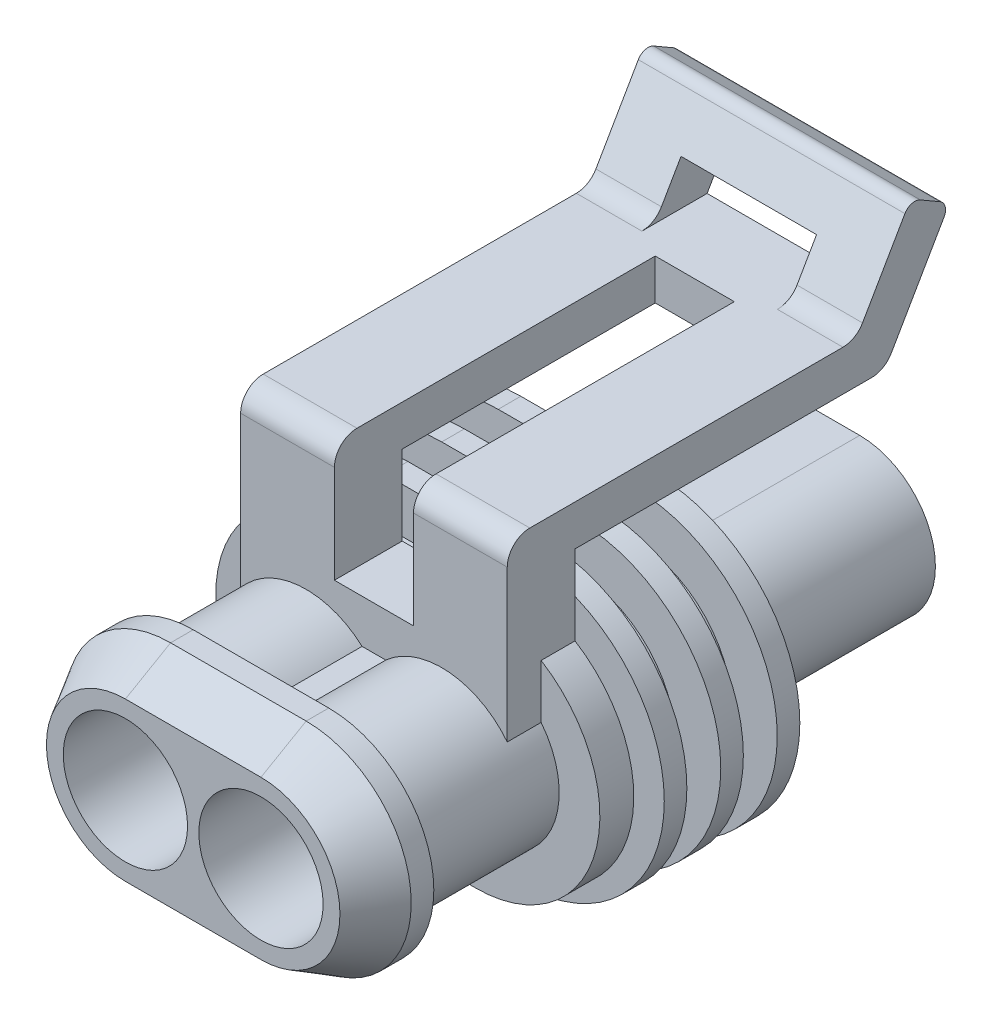
from build123d import *
from OCP.BRepFilletAPI import BRepFilletAPI_MakeChamfer

# Parameters (mm, degrees)
SKETCH1_R          = 2.75
EXTRUDE1_DEPTH     = 6.5
SKETCH2_R          = 2.75
EXTRUDE2_DEPTH     = 3
CHAMFER1_SIZE      = 2
CHAMFER1_SIZE2     = 1.154700538
SKETCH4_R          = 2.75
EXTRUDE3_DEPTH     = 1.5
EXTRUDE4_DEPTH     = 5.9
EXTRUDE5_DEPTH     = 15.5
CUT_EXTRUDE1_DEPTH = 3
CUT_EXTRUDE2_DEPTH = 1.75


with BuildPart() as part:
    # Sketch1 → Extrude1 (new body)
    with BuildSketch(Plane.XY):
        with BuildLine():
            Line((0.524621241, 2.75), (-0.524621241, 2.75))
            ThreePointArc((-0.524621241, 2.75), (-6.7, 0), (-0.524621241, -2.75))
            Line((-0.524621241, -2.75), (0.524621241, -2.75))
            ThreePointArc((0.524621241, -2.75), (6.7, 0), (0.524621241, 2.75))
        make_face()
        with Locations(Location((3, 0, 0), (0, 0, 180))):
            Circle(SKETCH1_R, mode=Mode.SUBTRACT)
        with Locations(Location((-3, 0, 0), (0, 0, 180))):
            Circle(SKETCH1_R, mode=Mode.SUBTRACT)
    extrude(amount=EXTRUDE1_DEPTH)

    # Sketch2 → Extrude2 (add)
    with BuildSketch(Plane.XY.offset(6.5)):
        with BuildLine():
            Line((3, 4.65), (-3, 4.65))
            ThreePointArc((-3, 4.65), (-7.65, 0), (-3, -4.65))
            Line((-3, -4.65), (3, -4.65))
            ThreePointArc((3, -4.65), (7.65, 0), (3, 4.65))
        make_face()
        with Locations(Location((3, 0, 0), (0, 0, 180))):
            Circle(SKETCH2_R, mode=Mode.SUBTRACT)
        with Locations(Location((-3, 0, 0), (0, 0, 180))):
            Circle(SKETCH2_R, mode=Mode.SUBTRACT)
    extrude(amount=EXTRUDE2_DEPTH)

    # Chamfer1: one chamfer whose edges measure the first distance from different faces: ONE call of the kernel's chamfer builder (chamfer() names one face for all edges)
    chamfer1_edges_1 = [part.edges().sort_by_distance(p)[0] for p in [
        (7.65, 0, 9.5),
    ]]
    chamfer1_side_1 = [part.faces().sort_by_distance(p)[0] for p in [
        (7.65, 0, 8),
    ]]
    chamfer1_edges_2 = [part.edges().sort_by_distance(p)[0] for p in [
        (0, 4.65, 9.5),
    ]]
    chamfer1_side_2 = [part.faces().sort_by_distance(p)[0] for p in [
        (0, 4.65, 8),
    ]]
    chamfer1_edges_3 = [part.edges().sort_by_distance(p)[0] for p in [
        (-7.65, 0, 9.5),
    ]]
    chamfer1_side_3 = [part.faces().sort_by_distance(p)[0] for p in [
        (-7.65, 0, 8),
    ]]
    chamfer1_edges_4 = [part.edges().sort_by_distance(p)[0] for p in [
        (0, -4.65, 9.5),
    ]]
    chamfer1_side_4 = [part.faces().sort_by_distance(p)[0] for p in [
        (0, -4.65, 8),
    ]]
    chamfer1 = BRepFilletAPI_MakeChamfer(part.part.solid().wrapped)
    for e in chamfer1_edges_1:
        chamfer1.Add(CHAMFER1_SIZE, CHAMFER1_SIZE2, e.wrapped, chamfer1_side_1[0].wrapped)  # the first distance lies on this face
    for e in chamfer1_edges_2:
        chamfer1.Add(CHAMFER1_SIZE, CHAMFER1_SIZE2, e.wrapped, chamfer1_side_2[0].wrapped)  # the first distance lies on this face
    for e in chamfer1_edges_3:
        chamfer1.Add(CHAMFER1_SIZE, CHAMFER1_SIZE2, e.wrapped, chamfer1_side_3[0].wrapped)  # the first distance lies on this face
    for e in chamfer1_edges_4:
        chamfer1.Add(CHAMFER1_SIZE, CHAMFER1_SIZE2, e.wrapped, chamfer1_side_4[0].wrapped)  # the first distance lies on this face
    add(Compound.cast(chamfer1.Shape()), mode=Mode.REPLACE)

    # Sketch4 → Extrude3 (add)
    with BuildSketch(Plane(origin=(0, 0, 0), x_dir=(-1, 0, 0), z_dir=(0, 0, -1))):
        with BuildLine():
            Line((3, 5.5), (-3, 5.5))
            ThreePointArc((-3, 5.5), (-8.5, 0), (-3, -5.5))
            Line((-3, -5.5), (3, -5.5))
            ThreePointArc((3, -5.5), (8.5, 0), (3, 5.5))
        make_face()
        with Locations((3, 0)):
            Circle(SKETCH4_R, mode=Mode.SUBTRACT)
        with Locations((-3, 0)):
            Circle(SKETCH4_R, mode=Mode.SUBTRACT)
    extrude(amount=EXTRUDE3_DEPTH)

    # Sketch5 → Extrude4 (add, symmetric)
    with BuildSketch(Plane(origin=(0, 0, 0), x_dir=(0, 0, -1), z_dir=(1, 0, 0))):
        with BuildLine():
            Line((1.5, 0), (1.5, 8.2))
            Line((1.5, 8.2), (14.628718708, 8.2))
            ThreePointArc((14.628718708, 8.2), (15.128718708, 8.333974596), (15.494744112, 8.7))
            Line((15.494744112, 8.7), (17.833012702, 12.75))
            ThreePointArc((17.833012702, 12.75), (17.882962913, 13.129409523), (17.65, 13.433012702))
            Line((17.65, 13.433012702), (16.783974596, 13.933012702))
            ThreePointArc((16.783974596, 13.933012702), (16.404565074, 13.982962913), (16.100961894, 13.75))
            Line((16.100961894, 13.75), (14.224573519, 10.5))
            ThreePointArc((14.224573519, 10.5), (13.858548116, 10.133974596), (13.358548116, 10))
            Line((13.358548116, 10), (-0.5, 10))
            ThreePointArc((-0.5, 10), (-1.207106781, 9.707106781), (-1.5, 9))
            Line((-1.5, 9), (-1.5, 0))
            Line((-1.5, 0), (1.5, 0))
        make_face()
    extrude(amount=EXTRUDE4_DEPTH, both=True)

    # Sketch6 → Extrude5 (add)
    with BuildSketch(Plane(origin=(0, 0, -1.5), x_dir=(-1, 0, 0), z_dir=(0, 0, -1))):
        with BuildLine():
            Line((-3, 3.35), (3, 3.35))
            ThreePointArc((3, 3.35), (6.35, 0), (3, -3.35))
            Line((3, -3.35), (-3, -3.35))
            ThreePointArc((-3, -3.35), (-6.35, 0), (-3, 3.35))
        make_face()
    extrude(amount=EXTRUDE5_DEPTH)

    # Sketch10 → Cut-Extrude1 (cut, symmetric)
    with BuildSketch(Plane(origin=(0, 0, 0), x_dir=(0, 0, -1), z_dir=(1, 0, 0))):
        Polygon((17.4, 12), (15.090598923, 12), (13.358548116, 10), (16.245299462, 10), align=None)
    extrude(amount=CUT_EXTRUDE1_DEPTH, both=True, mode=Mode.SUBTRACT)

    # Sketch11 → Cut-Extrude2 (cut, symmetric)
    with BuildSketch(Plane(origin=(0, 0, 0), x_dir=(0, 0, -1), z_dir=(1, 0, 0))):
        Polygon((1.5, 4.673328578), (-1.5, 4.673328578), (-1.5, 10), (12.7, 10), (12.7, 8.2), (1.5, 8.2), align=None)
    extrude(amount=CUT_EXTRUDE2_DEPTH, both=True, mode=Mode.SUBTRACT)

    # Bælg: sweep along a path in Sketch8
    with BuildLine(Plane(origin=(0, 0, -1.5), x_dir=(-1, 0, 0), z_dir=(0, 0, -1))) as b_lg_path:
        Line((3, 3.35), (-3, 3.35))
        ThreePointArc((-3, 3.35), (-6.35, 0), (-3, -3.35))
        Line((-3, -3.35), (3, -3.35))
        ThreePointArc((3, -3.35), (6.35, 0), (3, 3.35))
    # Sketch7 → Bælg (sweep)
    with BuildSketch(Plane(origin=(0, 0, 0), x_dir=(0, 0, -1), z_dir=(1, 0, 0))):
        Polygon((8.5, 3.35), (1.5, 3.35), (1.5, 4.35), (2, 4.35), (2, 6.35), (3, 6.35), (3, 4.35), (4.5, 4.35), (4.5, 6.35), (5.5, 6.35), (5.5, 4.35), (7, 4.35), (7, 6.35), (8, 6.35), (8, 4.35), (8.5, 4.35), align=None)
    sweep(path=b_lg_path.line)


solid = part.part
